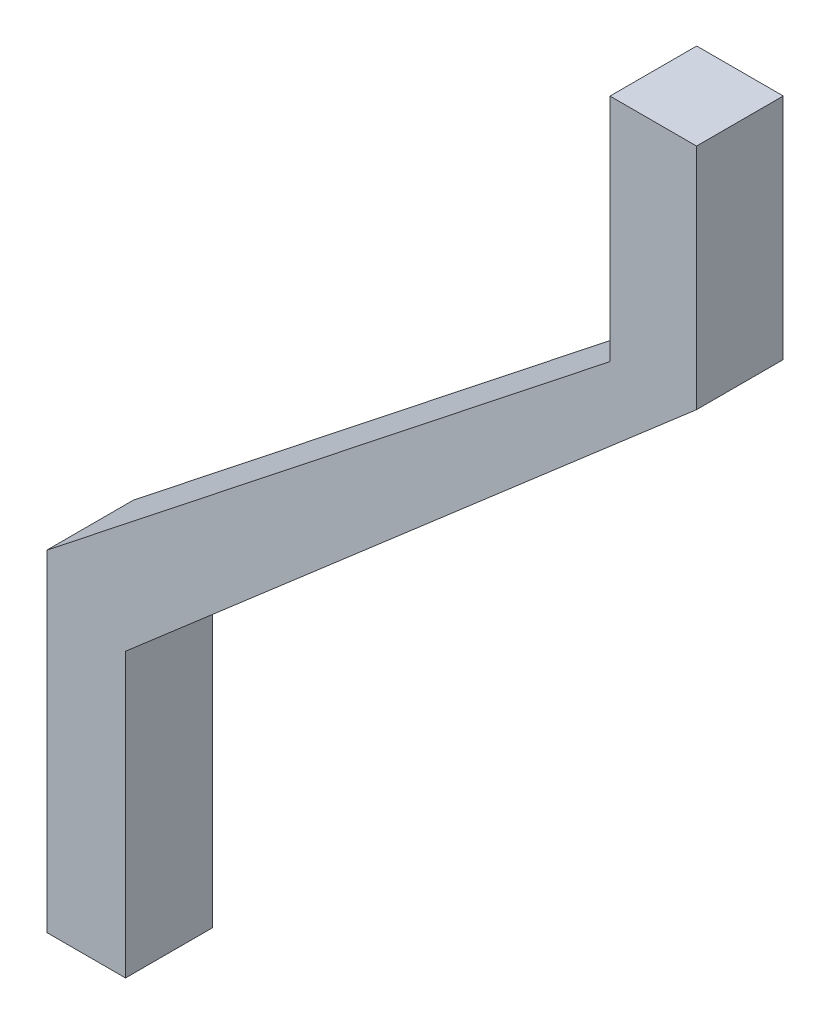
from build123d import *

# Parameters (mm, degrees)
BOSS_EXTRUDE1_DEPTH = 10


with BuildPart() as part:
    # Sketch1 → Boss-Extrude1 (new body)
    with BuildSketch(Plane.XY):
        Polygon((0, 0), (0, -26.520588235), (-64.946164547, -77.818627451), (-64.946164547, -116.003294118), (-55.861929253, -116.003294118), (-55.861929253, -83.371764706), (9.980588437, -26.329237427), (9.980588437, 0), align=None)
    extrude(amount=BOSS_EXTRUDE1_DEPTH)


solid = part.part
